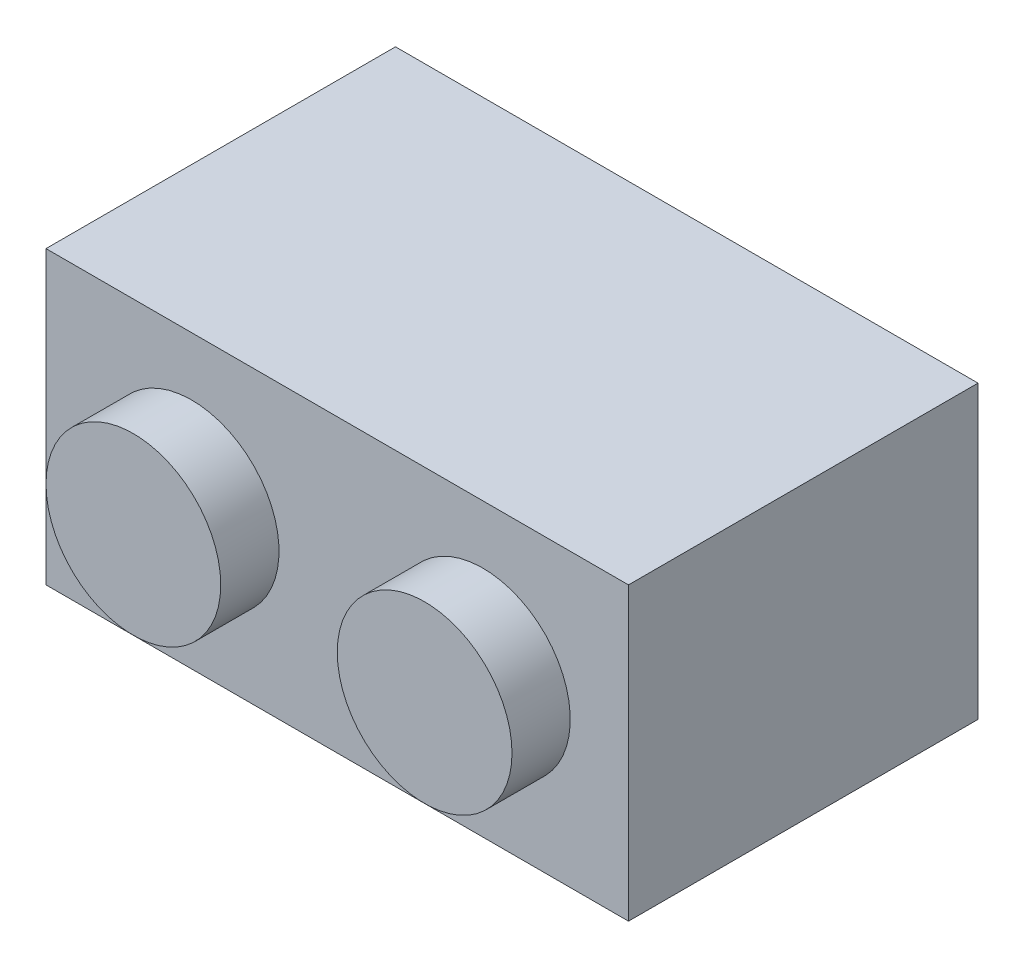
from build123d import *

# Parameters (mm, degrees)
SKETCH1_W           = 15.875
SKETCH1_H           = 7.9375
BOSS_EXTRUDE1_DEPTH = 9.525
SKETCH2_R           = 2.38125
BOSS_EXTRUDE2_DEPTH = 1.5875
LPATTERN1_COUNT     = 2
LPATTERN1_PITCH     = 7.9375
SHELL3_T            = -1.5875
SKETCH3_R           = 1.5875
BOSS_EXTRUDE3_DEPTH = 7.9375


with BuildPart() as part:
    # Sketch1 → Boss-Extrude1 (new body)
    with BuildSketch(Plane.XY):
        with Locations((7.9375, 3.96875)):
            Rectangle(SKETCH1_W, SKETCH1_H)
    extrude(amount=BOSS_EXTRUDE1_DEPTH)

    # Sketch2 → Boss-Extrude2 (add)
    with BuildSketch(Plane.XY.offset(9.525)):
        with Locations((3.96875, 3.96875)):
            Circle(SKETCH2_R)
    boss_extrude2 = extrude(amount=BOSS_EXTRUDE2_DEPTH)

    # LPattern1: Boss-Extrude2 ×2
    with Locations(*[(i * LPATTERN1_PITCH, 0, 0) for i in range(1, LPATTERN1_COUNT)]):
        add(boss_extrude2)

    # Shell3
    shell3_openings = [part.faces().sort_by_distance(p)[0] for p in [
        (7.9375, 3.96875, 0),
    ]]
    offset(amount=SHELL3_T, openings=shell3_openings, kind=Kind.INTERSECTION)

    # Sketch3 → Boss-Extrude3 (add)
    with BuildSketch(Plane(origin=(0, 0, 7.9375), x_dir=(-1, 0, 0), z_dir=(0, 0, -1))):
        with Locations((-7.9375, 3.96875)):
            Circle(SKETCH3_R)
    extrude(amount=BOSS_EXTRUDE3_DEPTH)


solid = part.part
